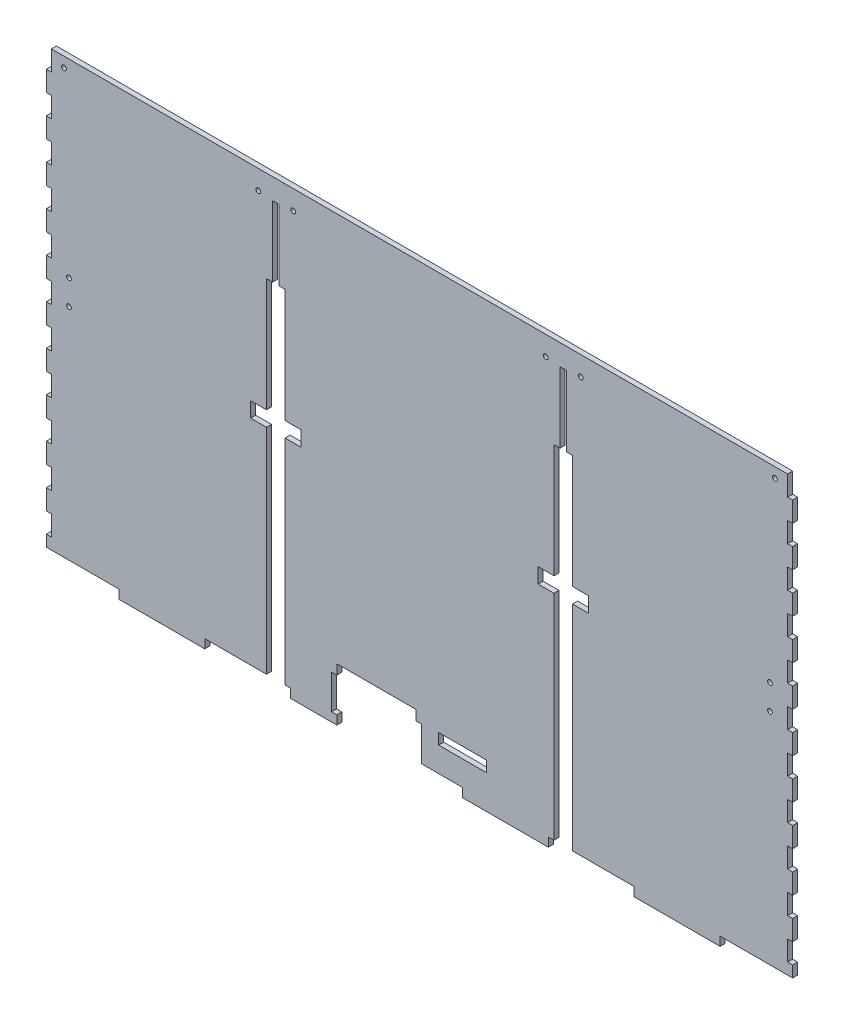
from build123d import *

# Parameters (mm, degrees)
SKETCH1_W                    = 3.175
SKETCH1_H                    = 12.7
MAIN_EXTRUDE_DEPTH           = 3.175
SKETCH8_R                    = 1.5
SKETCH8_W                    = 3.175
SKETCH8_H                    = 31.877
MOUNT_HOLES_DEPTH            = 430.752406189
DOOR_SLOTS_DEPTH             = 430.752406189
SKETCH4_W                    = 30.099999998
SKETCH4_H                    = 6.858
TROUGH_AND_LEVER_HOLES_DEPTH = 430.752406189
SKETCH10_R                   = 1.5
DOOR_GUIDE_MOUNT_HOLES_DEPTH = 430.752406189
SKETCH12_R                   = 1.5
EXTENSION_CLIP_HOLES_DEPTH   = 430.752406189
EXTENSION_CENTER_CUT_DEPTH   = 430.752406189


with BuildPart() as part:
    # Sketch1 → Main Extrude (new body)
    with BuildSketch(Plane.XY):
        Polygon((-381, 139.7), (-406.4, 139.7), (-406.4, -139.7), (-352.213333333, -139.7), (-352.213333333, -134.112), (-298.026666667, -134.112), (-298.026666667, -139.7), (-243.84, -139.7), (-243.84, -134.112), (-189.653333333, -134.112), (-189.653333333, -139.7), (-135.466666667, -139.7), (-135.466666667, -134.112), (-81.28, -134.112), (-81.28, -139.7), (-27.093333333, -139.7), (-27.093333333, -134.112), (27.093333333, -134.112), (27.093333333, -139.7), (81.28, -139.7), (81.28, -134.112), (135.466666667, -134.112), (135.466666667, -139.7), (189.653333333, -139.7), (189.653333333, -134.112), (243.84, -134.112), (243.84, -139.7), (298.026666667, -139.7), (298.026666667, -134.112), (352.213333333, -134.112), (352.213333333, -139.7), (406.4, -139.7), (406.4, 139.7), (381, 139.7), (381, 127), (377.825, 127), (377.825, 139.7), (-377.825, 139.7), (-377.825, 127), (-381, 127), align=None)
        with Locations((-379.4125, 107.95)):
            Rectangle(SKETCH1_W, SKETCH1_H, mode=Mode.SUBTRACT)
        with Locations((-379.4125, 82.55)):
            Rectangle(SKETCH1_W, SKETCH1_H, mode=Mode.SUBTRACT)
        with Locations((-379.4125, 57.15)):
            Rectangle(SKETCH1_W, SKETCH1_H, mode=Mode.SUBTRACT)
        with Locations((-379.4125, 31.75)):
            Rectangle(SKETCH1_W, SKETCH1_H, mode=Mode.SUBTRACT)
        with Locations((-379.4125, 6.35)):
            Rectangle(SKETCH1_W, SKETCH1_H, mode=Mode.SUBTRACT)
        with Locations((-379.4125, -19.05)):
            Rectangle(SKETCH1_W, SKETCH1_H, mode=Mode.SUBTRACT)
        with Locations((-379.4125, -44.45)):
            Rectangle(SKETCH1_W, SKETCH1_H, mode=Mode.SUBTRACT)
        with Locations((-379.4125, -69.85)):
            Rectangle(SKETCH1_W, SKETCH1_H, mode=Mode.SUBTRACT)
        with Locations((-379.4125, -95.25)):
            Rectangle(SKETCH1_W, SKETCH1_H, mode=Mode.SUBTRACT)
        with Locations((-379.4125, -120.65)):
            Rectangle(SKETCH1_W, SKETCH1_H, mode=Mode.SUBTRACT)
        with Locations((379.4125, 107.95)):
            Rectangle(SKETCH1_W, SKETCH1_H, mode=Mode.SUBTRACT)
        with Locations((379.4125, 82.55)):
            Rectangle(SKETCH1_W, SKETCH1_H, mode=Mode.SUBTRACT)
        with Locations((379.4125, 57.15)):
            Rectangle(SKETCH1_W, SKETCH1_H, mode=Mode.SUBTRACT)
        with Locations((379.4125, 31.75)):
            Rectangle(SKETCH1_W, SKETCH1_H, mode=Mode.SUBTRACT)
        with Locations((379.4125, 6.35)):
            Rectangle(SKETCH1_W, SKETCH1_H, mode=Mode.SUBTRACT)
        with Locations((379.4125, -19.05)):
            Rectangle(SKETCH1_W, SKETCH1_H, mode=Mode.SUBTRACT)
        with Locations((379.4125, -44.45)):
            Rectangle(SKETCH1_W, SKETCH1_H, mode=Mode.SUBTRACT)
        with Locations((379.4125, -69.85)):
            Rectangle(SKETCH1_W, SKETCH1_H, mode=Mode.SUBTRACT)
        with Locations((379.4125, -95.25)):
            Rectangle(SKETCH1_W, SKETCH1_H, mode=Mode.SUBTRACT)
        with Locations((379.4125, -120.65)):
            Rectangle(SKETCH1_W, SKETCH1_H, mode=Mode.SUBTRACT)
    extrude(amount=MAIN_EXTRUDE_DEPTH)

    # Sketch8 → Mount Holes (cut, through all)
    with BuildSketch(Plane.XY.offset(3.175)):
        with Locations((-393.7, -120.65)):
            Circle(SKETCH8_R)
        with Locations((393.7, -120.65)):
            Circle(SKETCH8_R)
        with Locations((-382.5875, 12.319)):
            Rectangle(SKETCH8_W, SKETCH8_H)
        with Locations((382.5875, 12.319)):
            Rectangle(SKETCH8_W, SKETCH8_H)
    extrude(amount=-MOUNT_HOLES_DEPTH, mode=Mode.SUBTRACT)

    # Sketch3 → Door Slots (cut, through all)
    with BuildSketch(Plane.XY.offset(3.175)):
        Polygon((-88.7095, 126.492), (-92.6465, 126.492), (-92.6465, 82.042), (-96.52, 82.042), (-96.52, 10.3505), (-106.553, 10.3505), (-106.553, 0.8255), (-96.52, 0.8255), (-96.52, -134.112), (-84.836, -134.112), (-84.836, 0.8255), (-74.803, 0.8255), (-74.803, 10.3505), (-84.836, 10.3505), (-84.836, 82.042), (-88.7095, 82.042), align=None)
        Polygon((92.6465, 126.492), (88.7095, 126.492), (88.7095, 82.042), (84.836, 82.042), (84.836, 10.3505), (74.803, 10.3505), (74.803, 0.8255), (84.836, 0.8255), (84.836, -134.112), (96.52, -134.112), (96.52, 0.8255), (106.553, 0.8255), (106.553, 10.3505), (96.52, 10.3505), (96.52, 82.042), (92.6465, 82.042), align=None)
    extrude(amount=-DOOR_SLOTS_DEPTH, mode=Mode.SUBTRACT)

    # Sketch4 → Trough and Lever Holes (cut, through all)
    with BuildSketch(Plane.XY):
        Polygon((-52.178, -112.41), (-55.48, -112.41), (-55.48, -134.112), (-52.178, -134.112), (-52.178, -139.7), (-2.178, -139.7), (-2.178, -134.112), (1.124, -134.112), (1.124, -112.41), (-2.178, -112.41), (-2.178, -106.172), (-52.178, -106.172), align=None)
        with Locations((27.178, -115.062)):
            Rectangle(SKETCH4_W, SKETCH4_H)
    extrude(amount=TROUGH_AND_LEVER_HOLES_DEPTH, mode=Mode.SUBTRACT)

    # Sketch10 → Door Guide Mount Holes (cut, through all)
    with BuildSketch(Plane.XY.offset(3.175)):
        with Locations((-101.678, 127.492)):
            Circle(SKETCH10_R)
        with Locations((-79.678, 127.492)):
            Circle(SKETCH10_R)
        with Locations((79.678, 127.492)):
            Circle(SKETCH10_R)
        with Locations((101.678, 127.492)):
            Circle(SKETCH10_R)
    extrude(amount=-DOOR_GUIDE_MOUNT_HOLES_DEPTH, mode=Mode.SUBTRACT)

    # Sketch12 → Extension Clip Holes (cut, through all)
    with BuildSketch(Plane.XY.offset(3.175)):
        with Locations((-246.507, 20.193)):
            Circle(SKETCH12_R)
        with Locations((-246.507, 4.445)):
            Circle(SKETCH12_R)
        with Locations((-221.107, 4.445)):
            Circle(SKETCH12_R)
        with Locations((-221.107, 20.193)):
            Circle(SKETCH12_R)
        with Locations((-243.332, 133.35)):
            Circle(SKETCH12_R)
        with Locations((-224.282, 133.35)):
            Circle(SKETCH12_R)
        with Locations((224.282, 133.35)):
            Circle(SKETCH12_R)
        with Locations((243.332, 133.35)):
            Circle(SKETCH12_R)
        with Locations((221.107, 20.193)):
            Circle(SKETCH12_R)
        with Locations((221.107, 4.445)):
            Circle(SKETCH12_R)
        with Locations((246.507, 4.445)):
            Circle(SKETCH12_R)
        with Locations((246.507, 20.193)):
            Circle(SKETCH12_R)
    extrude(amount=-EXTENSION_CLIP_HOLES_DEPTH, mode=Mode.SUBTRACT)

    # Sketch11_3 → Extension Center Cut (cut, through all)
    with BuildSketch(Plane.XY.offset(3.175)):
        Polygon((-232.2195, 127), (-232.2195, 139.7), (-406.4, 139.7), (-406.4, -139.7), (-235.3945, -139.7), (-235.3945, -127), (-232.2195, -127), (-232.2195, -114.3), (-235.3945, -114.3), (-235.3945, -101.6), (-232.2195, -101.6), (-232.2195, -88.9), (-235.3945, -88.9), (-235.3945, -76.2), (-232.2195, -76.2), (-232.2195, -63.5), (-235.3945, -63.5), (-235.3945, -50.8), (-232.2195, -50.8), (-232.2195, -38.1), (-235.3945, -38.1), (-235.3945, -25.4), (-232.2195, -25.4), (-232.2195, -12.7), (-235.3945, -12.7), (-235.3945, 0), (-232.2195, 0), (-232.2195, 12.7), (-235.3945, 12.7), (-235.3945, 25.4), (-232.2195, 25.4), (-232.2195, 38.1), (-235.3945, 38.1), (-235.3945, 50.8), (-232.2195, 50.8), (-232.2195, 63.5), (-235.3945, 63.5), (-235.3945, 76.2), (-232.2195, 76.2), (-232.2195, 88.9), (-235.3945, 88.9), (-235.3945, 101.6), (-232.2195, 101.6), (-232.2195, 114.3), (-235.3945, 114.3), (-235.3945, 127), align=None)
        Polygon((406.4, 139.7), (232.2195, 139.7), (232.2195, 127), (235.3945, 127), (235.3945, 114.3), (232.2195, 114.3), (232.2195, 101.6), (235.3945, 101.6), (235.3945, 88.9), (232.2195, 88.9), (232.2195, 76.2), (235.3945, 76.2), (235.3945, 63.5), (232.2195, 63.5), (232.2195, 50.8), (235.3945, 50.8), (235.3945, 38.1), (232.2195, 38.1), (232.2195, 25.4), (235.3945, 25.4), (235.3945, 12.7), (232.2195, 12.7), (232.2195, 0), (235.3945, 0), (235.3945, -12.7), (232.2195, -12.7), (232.2195, -25.4), (235.3945, -25.4), (235.3945, -38.1), (232.2195, -38.1), (232.2195, -50.8), (235.3945, -50.8), (235.3945, -63.5), (232.2195, -63.5), (232.2195, -76.2), (235.3945, -76.2), (235.3945, -88.9), (232.2195, -88.9), (232.2195, -101.6), (235.3945, -101.6), (235.3945, -114.3), (232.2195, -114.3), (232.2195, -127), (235.3945, -127), (235.3945, -139.7), (406.4, -139.7), align=None)
    extrude(amount=-EXTENSION_CENTER_CUT_DEPTH, mode=Mode.SUBTRACT)


solid = part.part
